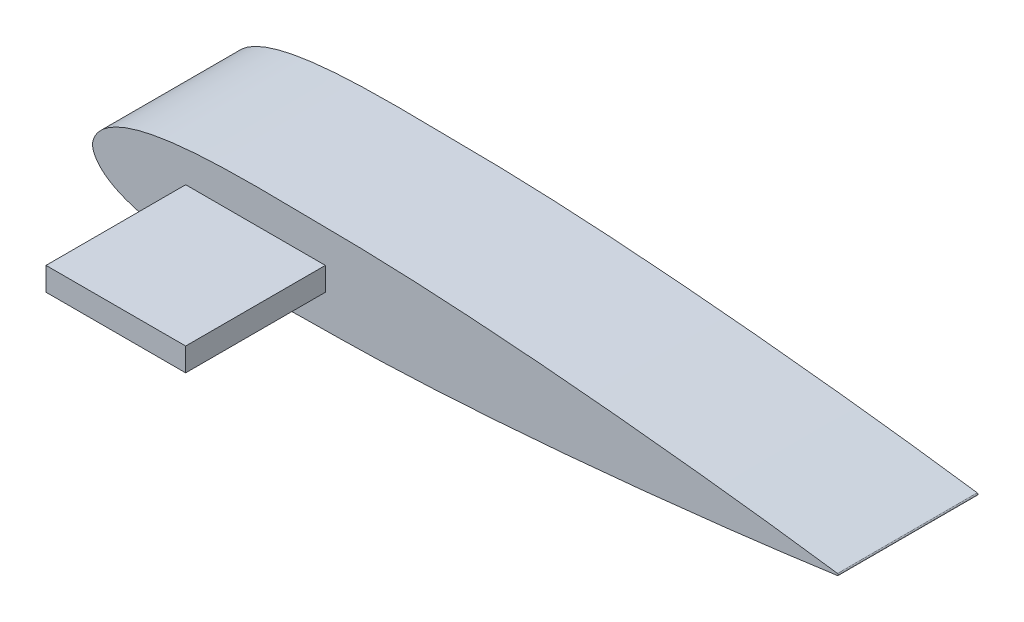
from build123d import *

# Parameters (mm, degrees)
BOSS_EXTRUDE1_DEPTH        = 4.7625
SCALE2_SCALE               = 4
SKETCH8_W                  = 19.05
SKETCH8_H                  = 3.175
BOSS_EXTRUDE2_DEPTH        = 19.05
SKETCH9_R                  = 5.55625
CUT_EXTRUDE2_DEPTH         = 12.7
F_8_CLEARANCE_HOLE1_REACH  = 110.79
F_8_CLEARANCE_HOLE1_BORE_R = 2.15265


with BuildPart() as part:
    # Sketch1 → Boss-Extrude1 (new body)
    with BuildSketch(Plane.XY):
        with BuildLine():
            ThreePointArc((25.4, 0.032004), (25.4278925, 0), (25.4, -0.032004))
            add(Edge.make_bspline(
                [(25.4, 0.032004), (24.976763142, 0.09038392), (24.130729118, 0.207083111), (22.860537314, 0.369075077), (21.590523122, 0.522945316), (20.320453908, 0.667553054), (19.050431345, 0.803987802), (17.780426045, 0.932064365), (16.510446035, 1.051439262), (15.240419108, 1.160633972), (13.970438163, 1.259826752), (12.691960705, 1.347295914), (11.413521526, 1.422148174), (10.134946596, 1.477569314), (8.864863209, 1.51851922), (7.814638679, 1.517803525), (6.976566881, 1.537320372), (6.350025451, 1.546044901), (5.715005509, 1.550632383), (5.079933925, 1.547825218), (4.444783021, 1.534647506), (3.809454821, 1.507826711), (3.173844139, 1.462008836), (2.580310634, 1.395935364), (2.02888213, 1.305517971), (1.605204868, 1.209099774), (1.2675404, 1.107010546), (1.01196949, 1.013602494), (0.754896685, 0.896473462), (0.493271227, 0.743000412), (0.276246151, 0.563513884), (0.08510933, 0.323263229), (-0.05557661, 0), (0.08510933, -0.323263229), (0.276246151, -0.563513884), (0.493271227, -0.743000412), (0.754896685, -0.896473462), (1.01196949, -1.013602494), (1.2675404, -1.107010546), (1.605204868, -1.209099774), (2.02888213, -1.305517971), (2.580310634, -1.395935364), (3.173844139, -1.462008836), (3.809454821, -1.507826711), (4.444783021, -1.534647506), (5.079933925, -1.547825218), (5.715005509, -1.550632383), (6.350025451, -1.546044901), (6.976566881, -1.537320372), (7.814638679, -1.517803525), (8.864863209, -1.51851922), (10.134946596, -1.477569314), (11.413521526, -1.422148174), (12.691960705, -1.347295914), (13.970438163, -1.259826752), (15.240419108, -1.160633972), (16.510446035, -1.051439262), (17.780426045, -0.932064365), (19.050431345, -0.803987802), (20.320453908, -0.667553054), (21.590523122, -0.522945316), (22.860537314, -0.369075077), (24.130729118, -0.207083111), (24.976763142, -0.09038392), (25.4, -0.032004)],
                knots=[0, 0, 0, 0, 0.024634231, 0.04924287, 0.07382978, 0.098396751, 0.122945996, 0.147478562, 0.171994581, 0.196493552, 0.220976186, 0.245442093, 0.270380478, 0.294812969, 0.319231823, 0.343641967, 0.355360378, 0.36756608, 0.379770767, 0.391975369, 0.404182653, 0.416398684, 0.428636132, 0.440920171, 0.450818129, 0.460843203, 0.465945571, 0.471149096, 0.476522598, 0.482208155, 0.488618357, 0.492567758, 0.5, 0.507432242, 0.511381643, 0.517791845, 0.523477402, 0.528850904, 0.534054429, 0.539156797, 0.549181871, 0.559079829, 0.571363868, 0.583601316, 0.595817347, 0.608024631, 0.620229233, 0.63243392, 0.644639622, 0.656358033, 0.680768177, 0.705187031, 0.729619522, 0.754557907, 0.779023814, 0.803506448, 0.828005419, 0.852521438, 0.877054004, 0.901603249, 0.92617022, 0.95075713, 0.975365769, 1, 1, 1, 1], degree=3))
        make_face()
    extrude(amount=BOSS_EXTRUDE1_DEPTH)


with BuildPart() as part_1:
    # Scale2: scaled about (0, 0, 0)
    add(part.part.scale(SCALE2_SCALE))

    # Sketch8 → Boss-Extrude2 (add)
    with BuildSketch(Plane.XY.offset(19.05)):
        with Locations((22.225, 0)):
            Rectangle(SKETCH8_W, SKETCH8_H)
    extrude(amount=BOSS_EXTRUDE2_DEPTH)

    # Sketch9 → Cut-Extrude2 (cut)
    with BuildSketch(Plane(origin=(0, 0, 0), x_dir=(-1, 0, 0), z_dir=(0, 0, -1))):
        with Locations((-22.225, 0)):
            Circle(SKETCH9_R)
    extrude(amount=-CUT_EXTRUDE2_DEPTH, mode=Mode.SUBTRACT)

    # #8 Clearance Hole1 bore → #8 Clearance Hole1 (cut, up to next)
    with BuildSketch(Plane(origin=(0, 0, 0), x_dir=(0, 0, -1), z_dir=(-1, 0, 0)), mode=Mode.PRIVATE) as f_8_clearance_hole1_sk1:
        with Locations((-6.35, 0)):
            Circle(F_8_CLEARANCE_HOLE1_BORE_R)
    f_8_clearance_hole1_tool1 = extrude(f_8_clearance_hole1_sk1.sketch, amount=-F_8_CLEARANCE_HOLE1_REACH, mode=Mode.PRIVATE) & part_1.part
    add(f_8_clearance_hole1_tool1.solids().sort_by_distance((0, 0, 6.35))[0], mode=Mode.SUBTRACT)


solid = part_1.part
